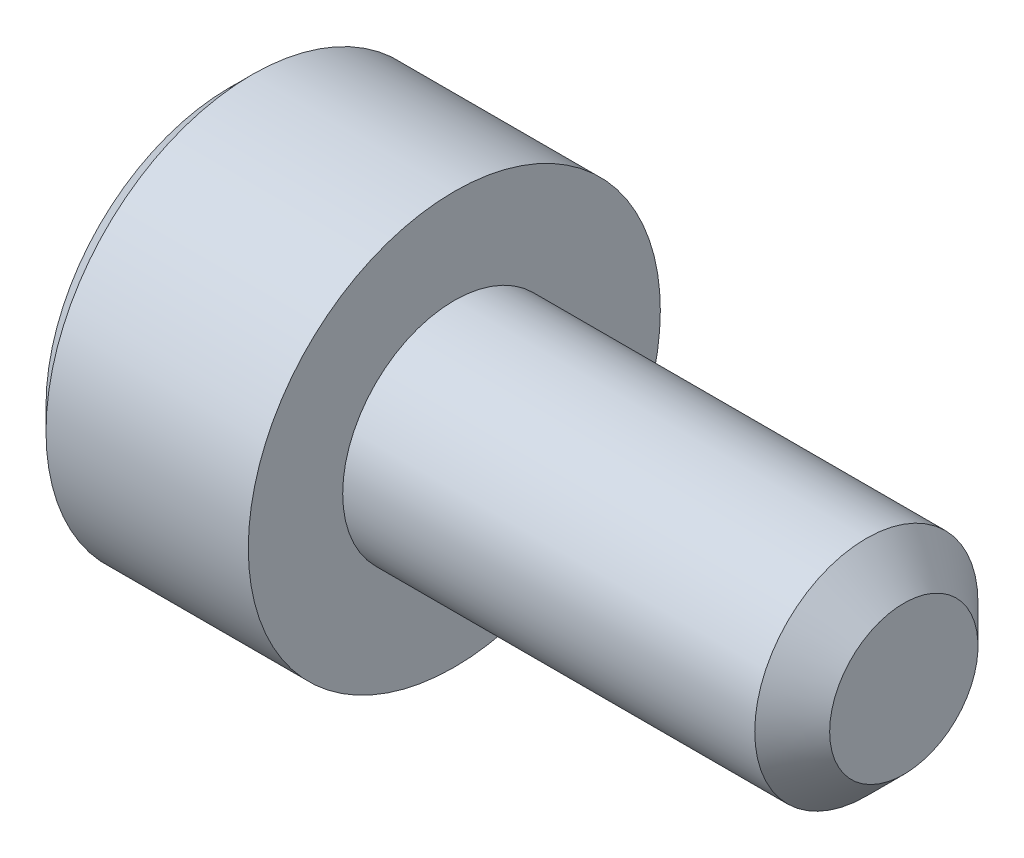
from build123d import *

# Parameters (mm, degrees)
CHAMFER1_SIZE      = 0.5
CHAMFER2_SIZE      = 0.3
CUT_EXTRUDE1_DEPTH = 2.5
CHAMFER3_SIZE      = 0.3


with BuildPart() as part:
    # Sketch1 → Revolve1 (revolve)
    with BuildSketch(Plane.XY):
        Polygon((0, 0), (0, 2.75), (3, 2.75), (3, 1.49), (9, 1.49), (9, 0), align=None)
    revolve(axis=Axis((-88.705490849, 0, 0), (1, 0, 0)))

    # Chamfer1
    chamfer1_edges = [part.edges().sort_by_distance(p)[0] for p in [
        (9, -1.49, 0),
    ]]
    chamfer(chamfer1_edges, length=CHAMFER1_SIZE)

    # Chamfer2
    chamfer2_edges = [part.edges().sort_by_distance(p)[0] for p in [
        (0, -2.75, 0),
    ]]
    chamfer(chamfer2_edges, length=CHAMFER2_SIZE)

    # Sketch3 → Cut-Extrude1 (cut)
    with BuildSketch(Plane(origin=(0, 0, 0), x_dir=(0, 0, -1), z_dir=(1, 0, 0))):
        Polygon((-1.443375673, 0), (-0.721687836, -1.25), (0.721687836, -1.25), (1.443375673, 0), (0.721687836, 1.25), (-0.721687836, 1.25), align=None)
    extrude(amount=CUT_EXTRUDE1_DEPTH, mode=Mode.SUBTRACT)

    # Chamfer3
    chamfer3_edges = [part.edges().sort_by_distance(p)[0] for p in [
        (0, 1.25, 0),
        (0, 0.625, 1.082531755),
        (0, -0.625, 1.082531755),
        (0, -1.25, 0),
        (0, -0.625, -1.082531755),
        (0, 0.625, -1.082531755),
    ]]
    chamfer(chamfer3_edges, length=CHAMFER3_SIZE)


solid = part.part
